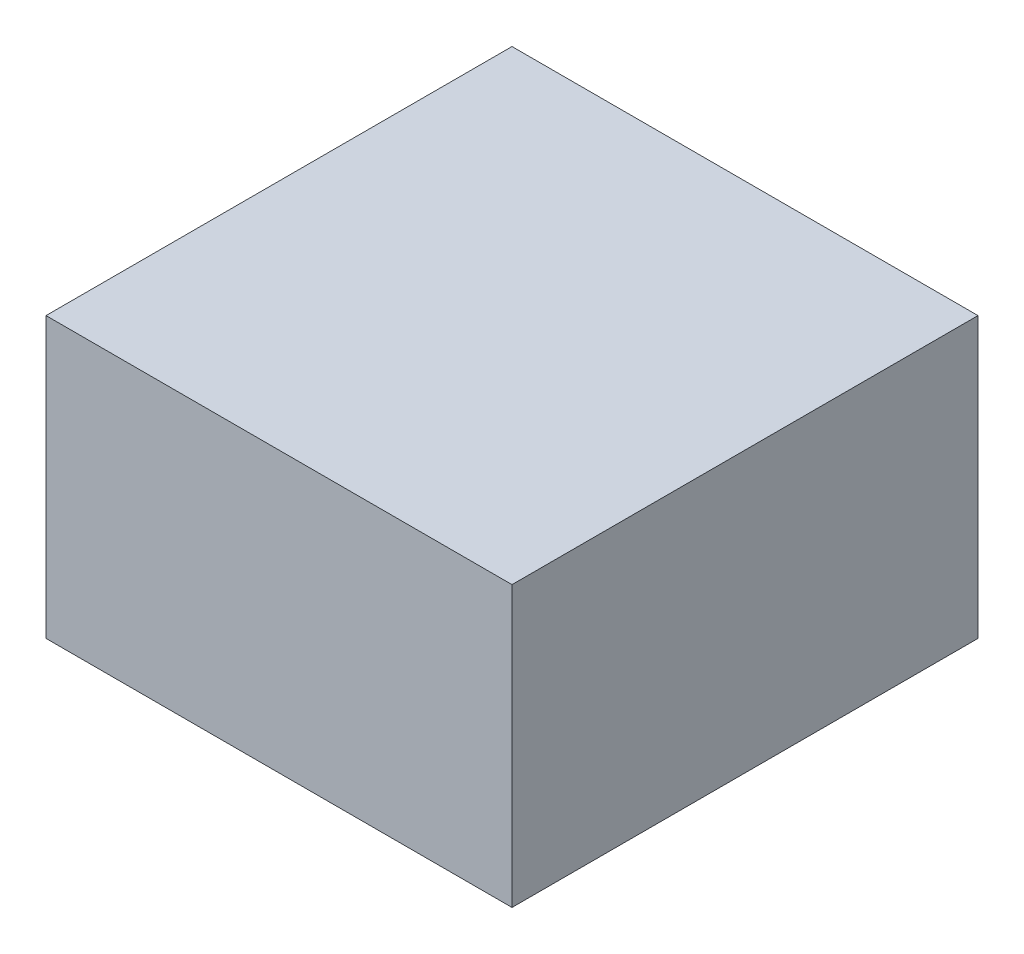
from build123d import *

# Parameters (mm, degrees)
SKETCH_1_W      = 50
SKETCH_1_H      = 30
EXTRUDE_1_DEPTH = 25


with BuildPart() as part:
    # Эскиз1 → Бобышка-Вытянуть1 (new body, symmetric)
    with BuildSketch(Plane.XY):
        Rectangle(SKETCH_1_W, SKETCH_1_H)
    extrude(amount=EXTRUDE_1_DEPTH, both=True)


solid = part.part
